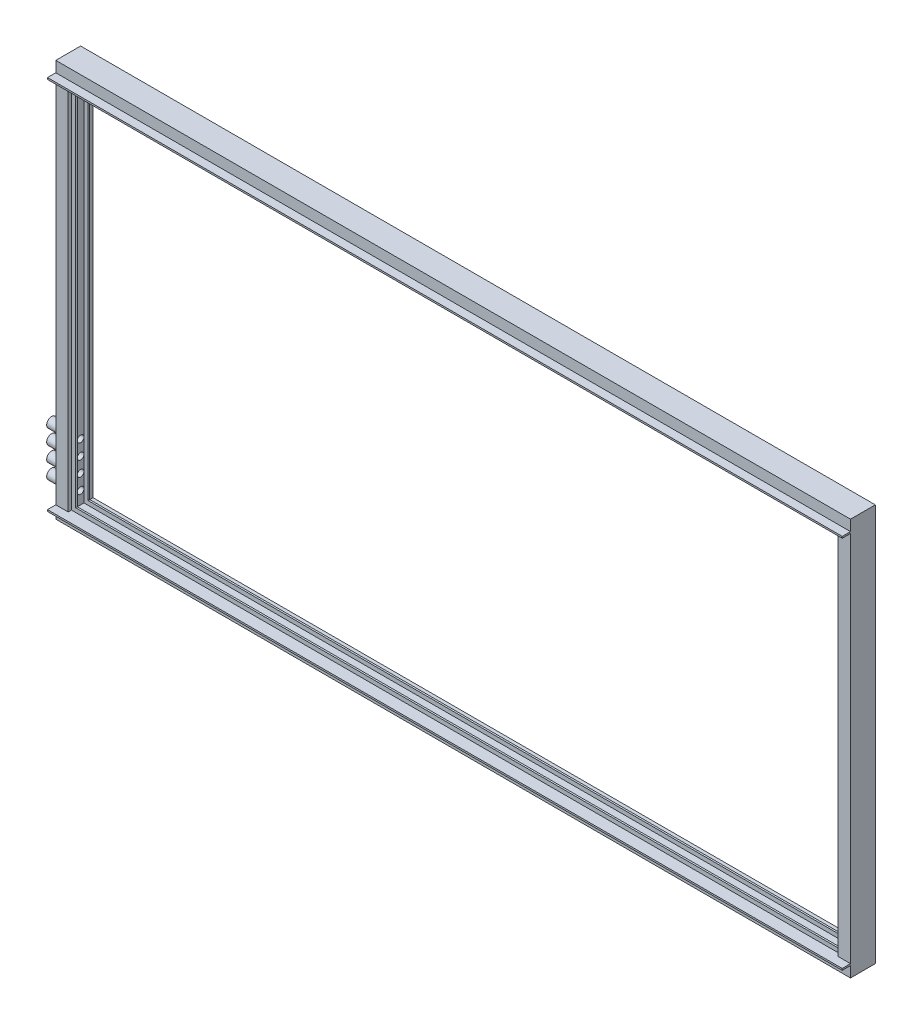
from build123d import *

# Parameters (mm, degrees)
CUT_EXTRUDE4_REACH  = 1221.2
SKETCH4_R           = 5.08
SKETCH5_R           = 7.62
SKETCH5_R_2         = 5.08
BOSS_EXTRUDE3_DEPTH = 25.4
SKETCH7_W           = 1219.2
SKETCH7_H           = 2.54
BOSS_EXTRUDE4_DEPTH = 12.7


with BuildPart() as part:
    # Sweep1: sweep along a path in Sketch2
    with BuildLine(Plane.XY) as sweep1_path:
        Line((609.6, -304.8), (-609.6, -304.8))
        Line((-609.6, -304.8), (-609.6, 304.8))
        Line((-609.6, 304.8), (609.6, 304.8))
        Line((609.6, 304.8), (609.6, -304.8))
    # Sketch3 → Sweep1 (sweep)
    with BuildSketch(Plane(origin=(0, 0, 0), x_dir=(0, 0, -1), z_dir=(1, 0, 0))):
        Polygon((-19.05, 304.8), (19.05, 304.8), (19.05, 285.75), (13.97, 285.75), (12.7, 287.02), (12.7, 297.18), (11.43, 298.45), (7.62, 298.45), (6.35, 297.18), (6.35, 287.02), (5.08, 285.75), (-5.08, 285.75), (-6.35, 287.02), (-6.35, 297.18), (-7.62, 298.45), (-11.43, 298.45), (-12.7, 297.18), (-12.7, 287.02), (-13.97, 285.75), (-19.05, 285.75), align=None)
    sweep(path=sweep1_path.line, transition=Transition.RIGHT)

    # Sketch4 → Cut-Extrude4 (cut, up to next)
    with BuildSketch(Plane.ZY.offset(609.6), mode=Mode.PRIVATE) as cut_extrude4_sk1:
        with Locations((0, -266.7)):
            Circle(SKETCH4_R)
    cut_extrude4_tool1 = extrude(cut_extrude4_sk1.sketch, amount=-CUT_EXTRUDE4_REACH, mode=Mode.PRIVATE) & part.part
    add(cut_extrude4_tool1.solids().sort_by_distance((-609.6, -266.7, 0))[0], mode=Mode.SUBTRACT)
    # Sketch4 → Cut-Extrude4 (cut, up to next)
    with BuildSketch(Plane.ZY.offset(609.6), mode=Mode.PRIVATE) as cut_extrude4_sk2:
        with Locations((0, -243.84)):
            Circle(SKETCH4_R)
    cut_extrude4_tool2 = extrude(cut_extrude4_sk2.sketch, amount=-CUT_EXTRUDE4_REACH, mode=Mode.PRIVATE) & part.part
    add(cut_extrude4_tool2.solids().sort_by_distance((-609.6, -243.84, 0))[0], mode=Mode.SUBTRACT)
    # Sketch4 → Cut-Extrude4 (cut, up to next)
    with BuildSketch(Plane.ZY.offset(609.6), mode=Mode.PRIVATE) as cut_extrude4_sk3:
        with Locations((0, -220.98)):
            Circle(SKETCH4_R)
    cut_extrude4_tool3 = extrude(cut_extrude4_sk3.sketch, amount=-CUT_EXTRUDE4_REACH, mode=Mode.PRIVATE) & part.part
    add(cut_extrude4_tool3.solids().sort_by_distance((-609.6, -220.98, 0))[0], mode=Mode.SUBTRACT)
    # Sketch4 → Cut-Extrude4 (cut, up to next)
    with BuildSketch(Plane.ZY.offset(609.6), mode=Mode.PRIVATE) as cut_extrude4_sk4:
        with Locations((0, -198.12)):
            Circle(SKETCH4_R)
    cut_extrude4_tool4 = extrude(cut_extrude4_sk4.sketch, amount=-CUT_EXTRUDE4_REACH, mode=Mode.PRIVATE) & part.part
    add(cut_extrude4_tool4.solids().sort_by_distance((-609.6, -198.12, 0))[0], mode=Mode.SUBTRACT)

    # Sketch5 → Boss-Extrude3 (add)
    with BuildSketch(Plane.ZY.offset(609.6)):
        with Locations((0, -198.12)):
            Circle(SKETCH5_R)
        with Locations((0, -198.12)):
            Circle(SKETCH5_R_2, mode=Mode.SUBTRACT)
        with Locations((0, -220.98)):
            Circle(SKETCH5_R)
        with Locations((0, -220.98)):
            Circle(SKETCH5_R_2, mode=Mode.SUBTRACT)
        with Locations((0, -243.84)):
            Circle(SKETCH5_R)
        with Locations((0, -243.84)):
            Circle(SKETCH5_R_2, mode=Mode.SUBTRACT)
        with Locations((0, -266.7)):
            Circle(SKETCH5_R)
        with Locations((0, -266.7)):
            Circle(SKETCH5_R_2, mode=Mode.SUBTRACT)
    extrude(amount=BOSS_EXTRUDE3_DEPTH)

    # Sketch7 → Boss-Extrude4 (add)
    with BuildSketch(Plane.XY.offset(19.05)):
        with Locations((0, 287.02)):
            Rectangle(SKETCH7_W, SKETCH7_H)
    boss_extrude4 = extrude(amount=BOSS_EXTRUDE4_DEPTH)

    # Mirror1: Boss-Extrude4 across plane
    add(boss_extrude4.mirror(Plane.ZX))


solid = part.part
